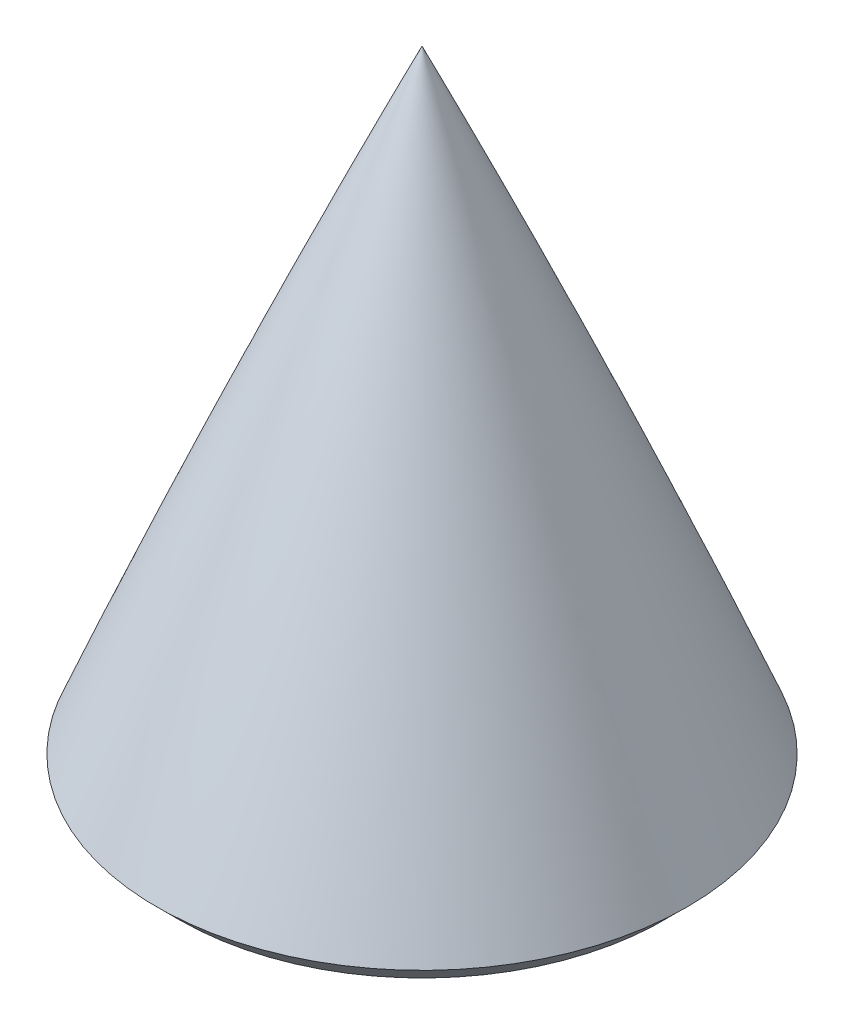
from build123d import *

# Parameters (mm, degrees)
SKETCH7_R          = 421.495799584
CUT_EXTRUDE2_DEPTH = 330.2
SKETCH8_R          = 2.413
CUT_EXTRUDE3_DEPTH = 12.7


with BuildPart() as part:
    # Sketch2 → Revolve1 (revolve)
    with BuildSketch(Plane.XY):
        with BuildLine():
            Line((-98.425, 0), (-90.551, 0))
            Line((-90.551, 0), (0, 0))
            Line((0, 0), (0, 375.92))
            Line((0, 375.92), (0, 381))
            ThreePointArc((0, 381), (-66.494117829, 194.964417939), (-98.425, 0))
        make_face()
    revolve(axis=Axis((0, 381, 0), (0, -1, 0)))

    # Sketch7 → Cut-Extrude2 (cut)
    with BuildSketch(Plane.XZ):
        with Locations((-188.314971498, 83.017725001)):
            Circle(SKETCH7_R)
    extrude(amount=-CUT_EXTRUDE2_DEPTH, mode=Mode.SUBTRACT)

    # Sketch8 → Cut-Extrude3 (cut)
    with BuildSketch(Plane(origin=(0, 330.2, 0), x_dir=(-1, 0, 0), z_dir=(0, -1, 0))):
        Circle(SKETCH8_R)
    extrude(amount=-CUT_EXTRUDE3_DEPTH, mode=Mode.SUBTRACT)

    # Sketch9 → Revolve2 (revolve)
    with BuildSketch(Plane.XY):
        Polygon((-20.066, 328.295), (-21.971, 330.2), (-18.161, 330.2), (-18.161, 328.295), align=None)
    revolve(axis=Axis((0, 330.842019051, 0), (0, -1, 0)))


solid = part.part
